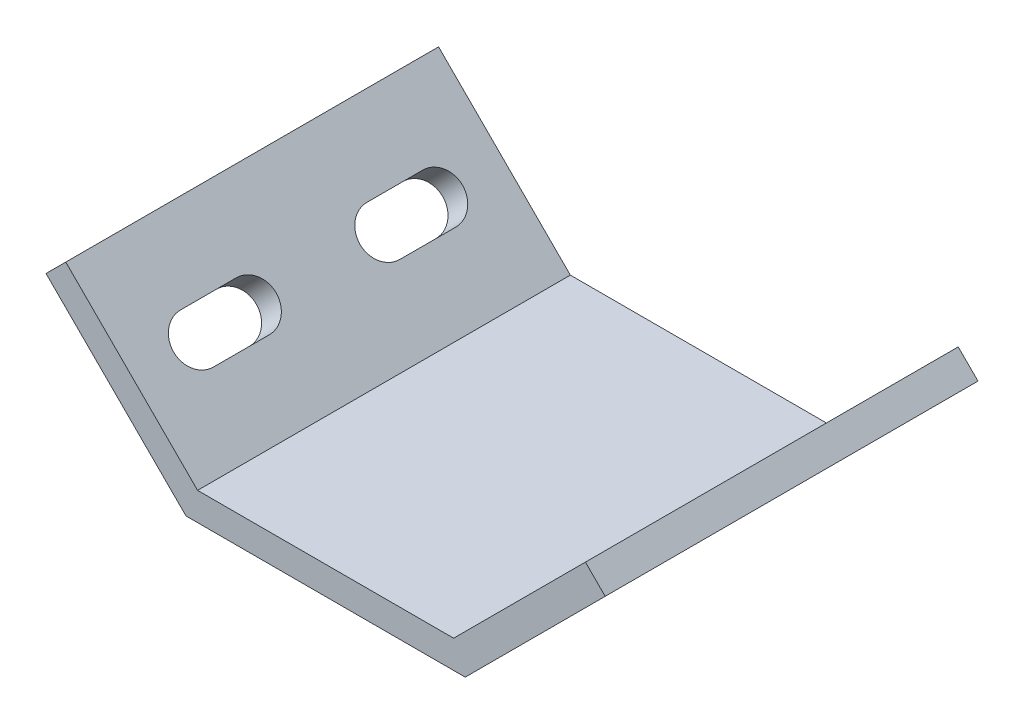
from build123d import *

# Parameters (mm, degrees)
EXTRUDE_1_DEPTH     = 20
CUT_EXTRUDE_1_DEPTH = 14.621320344


with BuildPart() as part:
    # Эскиз1 → Вытянуть-Тонкостенный1 (new body)
    with BuildSketch(Plane.XY):
        Polygon((-27.878679656, 14.142135624), (-13.736544033, 0), (13.736544033, 0), (27.878679656, 14.142135624), (30, 12.02081528), (14.97918472, -3), (-14.97918472, -3), (-30, 12.02081528), align=None)
    extrude(amount=EXTRUDE_1_DEPTH)

    # Эскиз2 → Вырез-Вытянуть1 (cut, through all)
    with BuildSketch(Plane(origin=(-6.868272016, -6.868272016, 0), x_dir=(0, 0, -1), z_dir=(0.707106781, 0.707106781, 0))):
        with BuildLine():
            Line((-7, 17.213203436), (-13, 17.213203436))
            ThreePointArc((-13, 17.213203436), (-15.5, 19.713203436), (-13, 22.213203436))
            Line((-13, 22.213203436), (-7, 22.213203436))
            ThreePointArc((-7, 22.213203436), (-4.5, 19.713203436), (-7, 17.213203436))
        make_face()
    cut_extrude_1 = extrude(amount=-CUT_EXTRUDE_1_DEPTH, mode=Mode.SUBTRACT)

    # Зеркальное отражение1: Вырез-Вытянуть1 across plane
    add(cut_extrude_1.mirror(Plane(origin=(0, 0, 0), x_dir=(0, 0, 1), z_dir=(1, 0, 0))), mode=Mode.SUBTRACT)

    # Зеркальное отражение2: part across plane


with BuildPart() as part_1:
    add(part.part)
    add(part.part.mirror(Plane(origin=(0, 0, 0), x_dir=(1, 0, 0), z_dir=(0, 0, -1))))


solid = part_1.part
